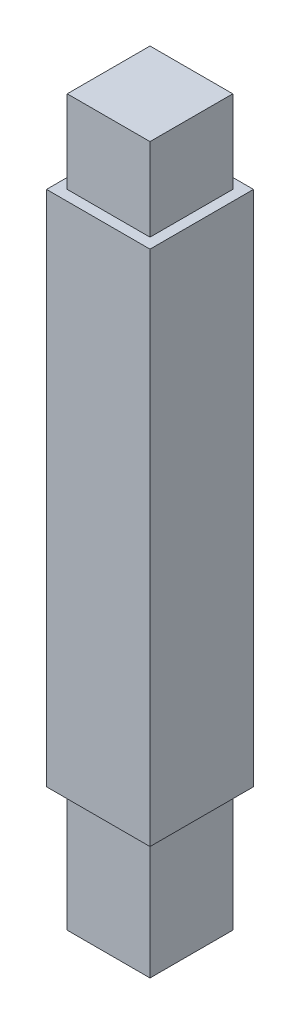
from build123d import *

# Parameters (mm, degrees)
SKETCH1_W           = 12.7
SKETCH1_H           = 63.5
BOSS_EXTRUDE1_DEPTH = 12.7
SKETCH2_W           = 10.16
SKETCH2_H           = 10.16
BOSS_EXTRUDE2_DEPTH = 10.16
SKETCH3_W           = 10.16
SKETCH3_H           = 10.16
BOSS_EXTRUDE3_DEPTH = 15.24


with BuildPart() as part:
    # Sketch1 → Boss-Extrude1 (new body)
    with BuildSketch(Plane.XY):
        with Locations((6.35, 31.75)):
            Rectangle(SKETCH1_W, SKETCH1_H)
    extrude(amount=BOSS_EXTRUDE1_DEPTH)

    # Sketch2 → Boss-Extrude2 (add)
    with BuildSketch(Plane(origin=(0, 63.5, 0), x_dir=(1, 0, 0), z_dir=(0, 1, 0))):
        with Locations((6.35, -6.35)):
            Rectangle(SKETCH2_W, SKETCH2_H)
    extrude(amount=BOSS_EXTRUDE2_DEPTH)

    # Sketch3 → Boss-Extrude3 (add)
    with BuildSketch(Plane.XZ):
        with Locations((6.35, 6.35)):
            Rectangle(SKETCH3_W, SKETCH3_H)
    extrude(amount=BOSS_EXTRUDE3_DEPTH)


solid = part.part
